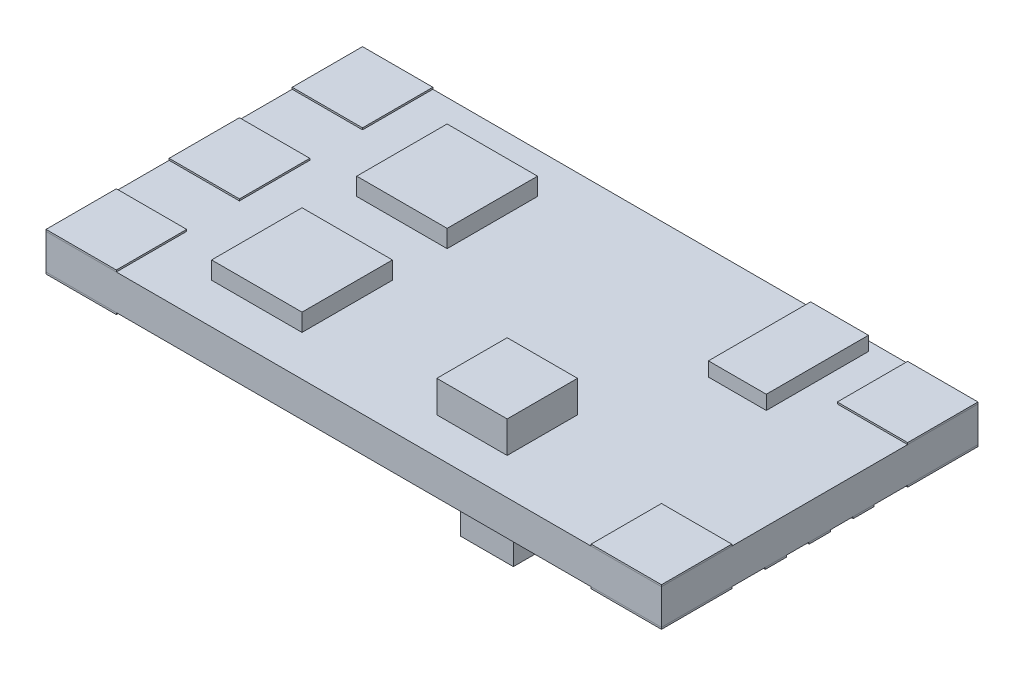
from build123d import *

# Parameters (mm, degrees)
SKETCH1_W             = 35
SKETCH1_H             = 18
BOSS_EXTRUDE1_DEPTH   = 2
SKETCH2_W             = 3.290634233
SKETCH2_H             = 5.810026068
BOSS_EXTRUDE2_DEPTH   = 0.8
SKETCH3_W             = 4
SKETCH3_H             = 4
BOSS_EXTRUDE3_DEPTH   = 1.8
SKETCH4_W             = 5.141615989
SKETCH4_H             = 5.141615989
BOSS_EXTRUDE4_DEPTH   = 1
BOSS_EXTRUDE4_2_DEPTH = 1
SKETCH5_W             = 4
SKETCH5_H             = 4
BOSS_EXTRUDE5_DEPTH   = 0.1
BOSS_EXTRUDE5_2_DEPTH = 0.1
BOSS_EXTRUDE5_3_DEPTH = 0.1
BOSS_EXTRUDE5_4_DEPTH = 0.1
BOSS_EXTRUDE5_5_DEPTH = 0.1
SKETCH6_W             = 6.694846846
SKETCH6_H             = 4.476078856
BOSS_EXTRUDE6_DEPTH   = 0.7
BOSS_EXTRUDE6_2_DEPTH = 0.7
BOSS_EXTRUDE6_3_DEPTH = 0.7
BOSS_EXTRUDE6_4_DEPTH = 0.7
BOSS_EXTRUDE6_5_DEPTH = 0.7
BOSS_EXTRUDE6_6_DEPTH = 0.7
SKETCH7_W             = 3
SKETCH7_H             = 1.6
BOSS_EXTRUDE7_DEPTH   = 1.8
BOSS_EXTRUDE7_2_DEPTH = 1.8
BOSS_EXTRUDE7_3_DEPTH = 1.8
BOSS_EXTRUDE7_4_DEPTH = 1.8
BOSS_EXTRUDE7_5_DEPTH = 1.8
BOSS_EXTRUDE7_6_DEPTH = 1.8
BOSS_EXTRUDE7_7_DEPTH = 1.8
BOSS_EXTRUDE7_8_DEPTH = 1.8
SKETCH8_W             = 2
SKETCH8_H             = 1.2
BOSS_EXTRUDE8_DEPTH   = 0.1
BOSS_EXTRUDE8_2_DEPTH = 0.1
BOSS_EXTRUDE8_3_DEPTH = 0.1
SKETCH9_W             = 2
SKETCH9_H             = 2
BOSS_EXTRUDE9_DEPTH   = 1


with BuildPart() as part:
    # Sketch1 → Boss-Extrude1 (new body)
    with BuildSketch(Plane(origin=(0, 0, 0), x_dir=(1, 0, 0), z_dir=(0, 1, 0))):
        Rectangle(SKETCH1_W, SKETCH1_H)
    extrude(amount=BOSS_EXTRUDE1_DEPTH)


with BuildPart() as body_2:
    # Sketch2 → Boss-Extrude2 (new body)
    with BuildSketch(Plane(origin=(0, 2, 0), x_dir=(1, 0, 0), z_dir=(0, 1, 0))):
        with Locations((10.154691578, 5.565799308)):
            Rectangle(SKETCH2_W, SKETCH2_H)
    extrude(amount=BOSS_EXTRUDE2_DEPTH)


with BuildPart() as body_3:
    # Sketch3 → Boss-Extrude3 (new body)
    with BuildSketch(Plane(origin=(0, 2, 0), x_dir=(1, 0, 0), z_dir=(0, 1, 0))):
        with Locations((4.647932234, -4.923097309)):
            Rectangle(SKETCH3_W, SKETCH3_H)
    extrude(amount=BOSS_EXTRUDE3_DEPTH)


with BuildPart() as body_4:
    # Sketch4 → Boss-Extrude4 (new body)
    with BuildSketch(Plane(origin=(0, 2, 0), x_dir=(1, 0, 0), z_dir=(0, 1, 0))):
        with Locations((-7.815256304, -4.126146832)):
            Rectangle(SKETCH4_W, SKETCH4_H)
    extrude(amount=BOSS_EXTRUDE4_DEPTH)


with BuildPart() as body_5:
    # Sketch4 → Boss-Extrude4 2 (new body)
    with BuildSketch(Plane(origin=(0, 2, 0), x_dir=(1, 0, 0), z_dir=(0, 1, 0))):
        with Locations((-7.815256304, 4.126146832)):
            Rectangle(SKETCH4_W, SKETCH4_H)
    extrude(amount=BOSS_EXTRUDE4_2_DEPTH)


with BuildPart() as body_6:
    # Sketch5 → Boss-Extrude5 (new body)
    with BuildSketch(Plane(origin=(0, 2, 0), x_dir=(1, 0, 0), z_dir=(0, 1, 0))):
        with Locations((-15.5, 7)):
            Rectangle(SKETCH5_W, SKETCH5_H)
    extrude(amount=BOSS_EXTRUDE5_DEPTH)


with BuildPart() as body_7:
    # Sketch5 → Boss-Extrude5 2 (new body)
    with BuildSketch(Plane(origin=(0, 2, 0), x_dir=(1, 0, 0), z_dir=(0, 1, 0))):
        with Locations((-15.5, 0)):
            Rectangle(SKETCH5_W, SKETCH5_H)
    extrude(amount=BOSS_EXTRUDE5_2_DEPTH)


with BuildPart() as body_8:
    # Sketch5 → Boss-Extrude5 3 (new body)
    with BuildSketch(Plane(origin=(0, 2, 0), x_dir=(1, 0, 0), z_dir=(0, 1, 0))):
        with Locations((15.5, -7)):
            Rectangle(SKETCH5_W, SKETCH5_H)
    extrude(amount=BOSS_EXTRUDE5_3_DEPTH)


with BuildPart() as body_9:
    # Sketch5 → Boss-Extrude5 4 (new body)
    with BuildSketch(Plane(origin=(0, 2, 0), x_dir=(1, 0, 0), z_dir=(0, 1, 0))):
        with Locations((-15.5, -7)):
            Rectangle(SKETCH5_W, SKETCH5_H)
    extrude(amount=BOSS_EXTRUDE5_4_DEPTH)


with BuildPart() as body_10:
    # Sketch5 → Boss-Extrude5 5 (new body)
    with BuildSketch(Plane(origin=(0, 2, 0), x_dir=(1, 0, 0), z_dir=(0, 1, 0))):
        with Locations((15.5, 7)):
            Rectangle(SKETCH5_W, SKETCH5_H)
    extrude(amount=BOSS_EXTRUDE5_5_DEPTH)


with BuildPart() as body_11:
    # Mirror1: mirrored copy
    add(body_6.part.mirror(Plane.ZX.offset(1)))


with BuildPart() as body_12:
    # Mirror1 2: mirrored copy
    add(body_7.part.mirror(Plane.ZX.offset(1)))


with BuildPart() as body_13:
    # Mirror1 3: mirrored copy
    add(body_9.part.mirror(Plane.ZX.offset(1)))


with BuildPart() as body_14:
    # Mirror1 4: mirrored copy
    add(body_10.part.mirror(Plane.ZX.offset(1)))


with BuildPart() as body_15:
    # Mirror1 5: mirrored copy
    add(body_8.part.mirror(Plane.ZX.offset(1)))


with BuildPart() as body_16:
    # Sketch6 → Boss-Extrude6 (new body)
    with BuildSketch(Plane.XZ):
        with Locations((-8.152576577, -6)):
            Rectangle(SKETCH6_W, SKETCH6_H)
    extrude(amount=BOSS_EXTRUDE6_DEPTH)


with BuildPart() as body_17:
    # Sketch6 → Boss-Extrude6 2 (new body)
    with BuildSketch(Plane.XZ):
        with Locations((-8.152576577, 6)):
            Rectangle(SKETCH6_W, SKETCH6_H)
    extrude(amount=BOSS_EXTRUDE6_2_DEPTH)


with BuildPart() as body_18:
    # Sketch6 → Boss-Extrude6 3 (new body)
    with BuildSketch(Plane.XZ):
        with Locations((-8.152576577, 0)):
            Rectangle(SKETCH6_W, SKETCH6_H)
    extrude(amount=BOSS_EXTRUDE6_3_DEPTH)


with BuildPart() as body_19:
    # Sketch6 → Boss-Extrude6 4 (new body)
    with BuildSketch(Plane.XZ):
        with Locations((0.152576577, -6)):
            Rectangle(SKETCH6_W, SKETCH6_H)
    extrude(amount=BOSS_EXTRUDE6_4_DEPTH)


with BuildPart() as body_20:
    # Sketch6 → Boss-Extrude6 5 (new body)
    with BuildSketch(Plane.XZ):
        with Locations((0.152576577, 0)):
            Rectangle(SKETCH6_W, SKETCH6_H)
    extrude(amount=BOSS_EXTRUDE6_5_DEPTH)


with BuildPart() as body_21:
    # Sketch6 → Boss-Extrude6 6 (new body)
    with BuildSketch(Plane.XZ):
        with Locations((0.152576577, 6)):
            Rectangle(SKETCH6_W, SKETCH6_H)
    extrude(amount=BOSS_EXTRUDE6_6_DEPTH)


with BuildPart() as body_22:
    # Sketch7 → Boss-Extrude7 (new body)
    with BuildSketch(Plane.XZ):
        with Locations((7, 5.444444444)):
            Rectangle(SKETCH7_W, SKETCH7_H)
    extrude(amount=BOSS_EXTRUDE7_DEPTH)


with BuildPart() as body_23:
    # Sketch7 → Boss-Extrude7 2 (new body)
    with BuildSketch(Plane.XZ):
        with Locations((7, 7.622222222)):
            Rectangle(SKETCH7_W, SKETCH7_H)
    extrude(amount=BOSS_EXTRUDE7_2_DEPTH)


with BuildPart() as body_24:
    # Sketch7 → Boss-Extrude7 3 (new body)
    with BuildSketch(Plane.XZ):
        with Locations((7, 3.266666667)):
            Rectangle(SKETCH7_W, SKETCH7_H)
    extrude(amount=BOSS_EXTRUDE7_3_DEPTH)


with BuildPart() as body_25:
    # Sketch7 → Boss-Extrude7 4 (new body)
    with BuildSketch(Plane.XZ):
        with Locations((7, 1.088888889)):
            Rectangle(SKETCH7_W, SKETCH7_H)
    extrude(amount=BOSS_EXTRUDE7_4_DEPTH)


with BuildPart() as body_26:
    # Sketch7 → Boss-Extrude7 5 (new body)
    with BuildSketch(Plane.XZ):
        with Locations((7, -1.088888889)):
            Rectangle(SKETCH7_W, SKETCH7_H)
    extrude(amount=BOSS_EXTRUDE7_5_DEPTH)


with BuildPart() as body_27:
    # Sketch7 → Boss-Extrude7 6 (new body)
    with BuildSketch(Plane.XZ):
        with Locations((7, -3.266666667)):
            Rectangle(SKETCH7_W, SKETCH7_H)
    extrude(amount=BOSS_EXTRUDE7_6_DEPTH)


with BuildPart() as body_28:
    # Sketch7 → Boss-Extrude7 7 (new body)
    with BuildSketch(Plane.XZ):
        with Locations((7, -5.444444444)):
            Rectangle(SKETCH7_W, SKETCH7_H)
    extrude(amount=BOSS_EXTRUDE7_7_DEPTH)


with BuildPart() as body_29:
    # Sketch7 → Boss-Extrude7 8 (new body)
    with BuildSketch(Plane.XZ):
        with Locations((7, -7.622222222)):
            Rectangle(SKETCH7_W, SKETCH7_H)
    extrude(amount=BOSS_EXTRUDE7_8_DEPTH)


with BuildPart() as body_30:
    # Sketch8 → Boss-Extrude8 (new body)
    with BuildSketch(Plane.XZ):
        with Locations((16.5, 0)):
            Rectangle(SKETCH8_W, SKETCH8_H)
    extrude(amount=BOSS_EXTRUDE8_DEPTH)


with BuildPart() as body_31:
    # Sketch8 → Boss-Extrude8 2 (new body)
    with BuildSketch(Plane.XZ):
        with Locations((16.5, 2.5)):
            Rectangle(SKETCH8_W, SKETCH8_H)
    extrude(amount=BOSS_EXTRUDE8_2_DEPTH)


with BuildPart() as body_32:
    # Sketch8 → Boss-Extrude8 3 (new body)
    with BuildSketch(Plane.XZ):
        with Locations((16.5, -2.5)):
            Rectangle(SKETCH8_W, SKETCH8_H)
    extrude(amount=BOSS_EXTRUDE8_3_DEPTH)


with BuildPart() as body_33:
    # Sketch9 → Boss-Extrude9 (new body)
    with BuildSketch(Plane.XZ):
        with Locations((12.5, 0)):
            Rectangle(SKETCH9_W, SKETCH9_H)
    extrude(amount=BOSS_EXTRUDE9_DEPTH)


solid = Compound([part.part, body_2.part, body_3.part, body_4.part, body_5.part, body_6.part, body_7.part, body_8.part, body_9.part, body_10.part, body_11.part, body_12.part, body_13.part, body_14.part, body_15.part, body_16.part, body_17.part, body_18.part, body_19.part, body_20.part, body_21.part, body_22.part, body_23.part, body_24.part, body_25.part, body_26.part, body_27.part, body_28.part, body_29.part, body_30.part, body_31.part, body_32.part, body_33.part])
